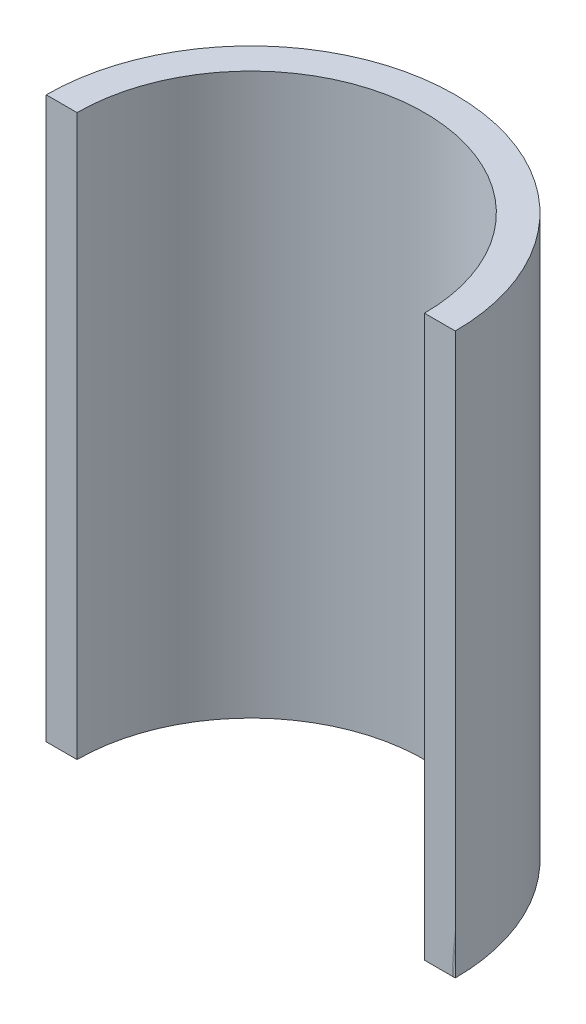
from build123d import *

# Parameters (mm, degrees)
SKETCH1_R           = 36.5
BOSS_EXTRUDE1_DEPTH = 100
SKETCH2_R           = 31
CUT_EXTRUDE2_DEPTH  = 101
CUT_EXTRUDE4_DEPTH  = 101


with BuildPart() as part:
    # Sketch1 → Boss-Extrude1 (new body)
    with BuildSketch(Plane(origin=(0, 0, 0), x_dir=(1, 0, 0), z_dir=(0, 1, 0))):
        Circle(SKETCH1_R)
    extrude(amount=BOSS_EXTRUDE1_DEPTH)

    # Sketch2 → Cut-Extrude2 (cut, through all)
    with BuildSketch(Plane(origin=(0, 0, 0), x_dir=(1, 0, 0), z_dir=(0, 1, 0))):
        Circle(SKETCH2_R)
    extrude(amount=CUT_EXTRUDE2_DEPTH, mode=Mode.SUBTRACT)

    # Sketch4 → Cut-Extrude4 (cut, through all)
    with BuildSketch(Plane(origin=(0, 0, 0), x_dir=(1, 0, 0), z_dir=(0, 1, 0))):
        with BuildLine():
            Line((36.5, 0), (-36.5, 0))
            ThreePointArc((-36.5, 0), (0, -36.5), (36.5, 0))
        make_face()
    extrude(amount=CUT_EXTRUDE4_DEPTH, mode=Mode.SUBTRACT)


solid = part.part
